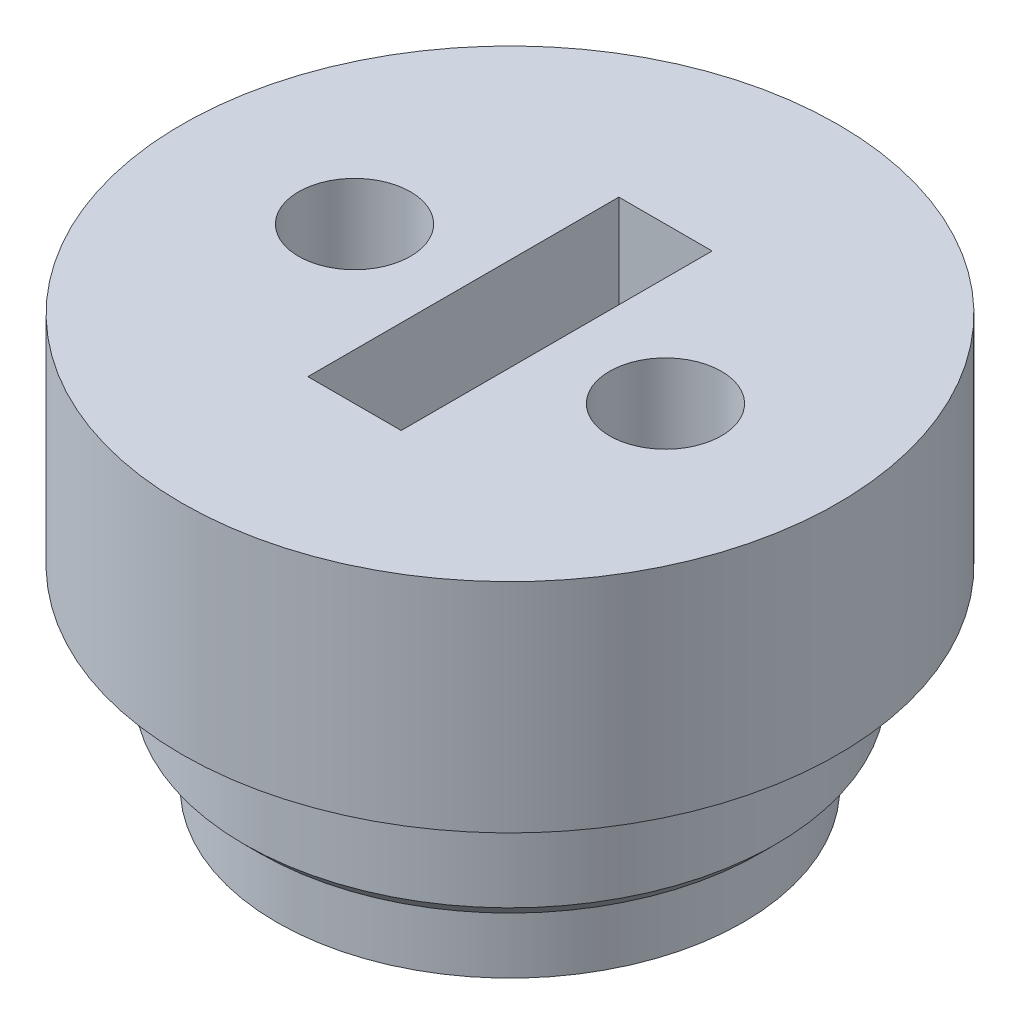
from build123d import *

# Parameters (mm, degrees)
SKIZZE1_R                       = 8.55
SKIZZE1_W                       = 3
SKIZZE1_H                       = 10
AUFSATZ_LINEAR_AUSTRAGEN1_DEPTH = 4
SKIZZE2_R                       = 10.55
SKIZZE2_W                       = 3
SKIZZE2_H                       = 10
AUFSATZ_LINEAR_AUSTRAGEN2_DEPTH = 7
SKIZZE3_R                       = 7.5
SKIZZE3_W                       = 3
SKIZZE3_H                       = 10
AUFSATZ_LINEAR_AUSTRAGEN3_DEPTH = 2.2
FASE1_SIZE                      = 0.5
SKIZZE4_R                       = 1.8
SCHNITT_LINEAR_AUSTRAGEN1_DEPTH = 10


with BuildPart() as part:
    # Skizze1 → Aufsatz-Linear austragen1 (new body)
    with BuildSketch(Plane(origin=(0, 0, 0), x_dir=(1, 0, 0), z_dir=(0, 1, 0))):
        Circle(SKIZZE1_R)
        Rectangle(SKIZZE1_W, SKIZZE1_H, mode=Mode.SUBTRACT)
    extrude(amount=AUFSATZ_LINEAR_AUSTRAGEN1_DEPTH)

    # Skizze2 → Aufsatz-Linear austragen2 (add)
    with BuildSketch(Plane(origin=(0, 4, 0), x_dir=(1, 0, 0), z_dir=(0, 1, 0))):
        Circle(SKIZZE2_R)
        Rectangle(SKIZZE2_W, SKIZZE2_H, mode=Mode.SUBTRACT)
    extrude(amount=AUFSATZ_LINEAR_AUSTRAGEN2_DEPTH)

    # Skizze3 → Aufsatz-Linear austragen3 (add)
    with BuildSketch(Plane.XZ):
        Circle(SKIZZE3_R)
        Rectangle(SKIZZE3_W, SKIZZE3_H, mode=Mode.SUBTRACT)
    extrude(amount=AUFSATZ_LINEAR_AUSTRAGEN3_DEPTH)

    # Fase1
    fase1_edges = [part.edges().sort_by_distance(p)[0] for p in [
        (-8.55, 0, 0),
    ]]
    chamfer(fase1_edges, length=FASE1_SIZE)

    # Skizze4 → Schnitt-Linear austragen1 (cut)
    with BuildSketch(Plane.XZ.offset(-11)):
        with Locations((-5, 0)):
            Circle(SKIZZE4_R)
        with Locations((5, 0)):
            Circle(SKIZZE4_R)
    extrude(amount=SCHNITT_LINEAR_AUSTRAGEN1_DEPTH, mode=Mode.SUBTRACT)


solid = part.part
